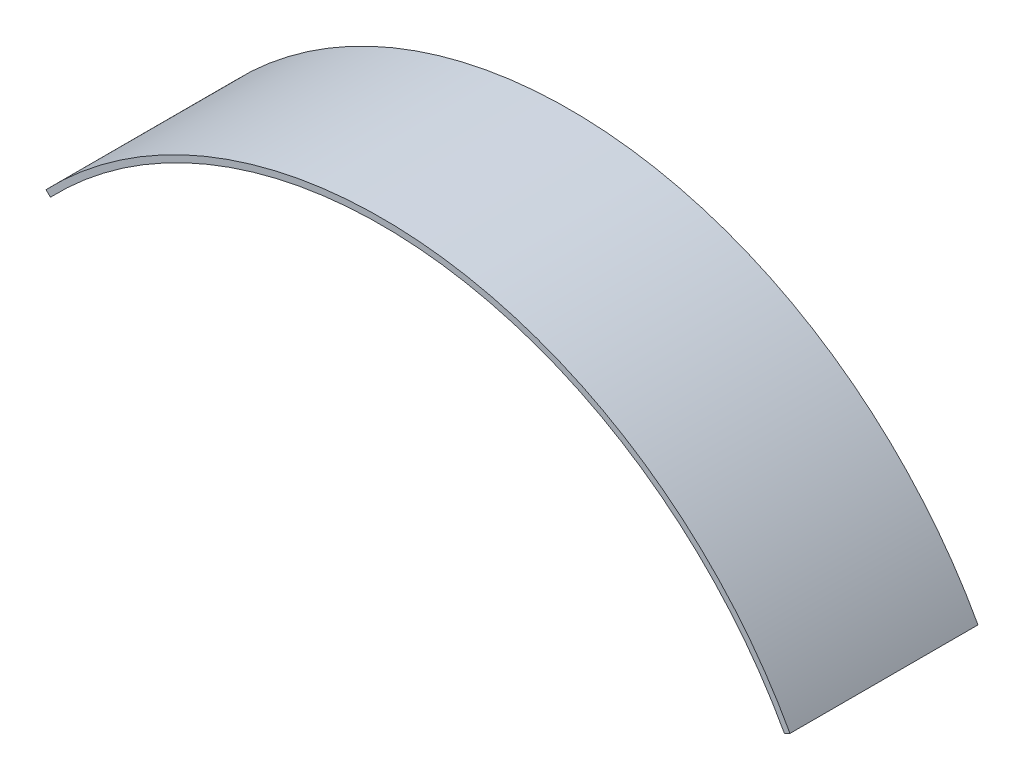
from build123d import *

# Parameters (mm, degrees)
BOSS_EXTRUDE1_DEPTH = 53


with BuildPart() as part:
    # Sketch1 → Boss-Extrude1 (new body)
    with BuildSketch(Plane.XY):
        with BuildLine():
            Line((0, 0), (1.26370527, -1.210598608))
            ThreePointArc((1.26370527, -1.210598608), (111.698368144, 37.522963954), (208.173780211, -28.723534063))
            Line((208.173780211, -28.723534063), (209.709928636, -27.885233391))
            ThreePointArc((209.709928636, -27.885233391), (111.92903621, 39.257695127), (0, 0))
        make_face()
    extrude(amount=BOSS_EXTRUDE1_DEPTH)


solid = part.part
